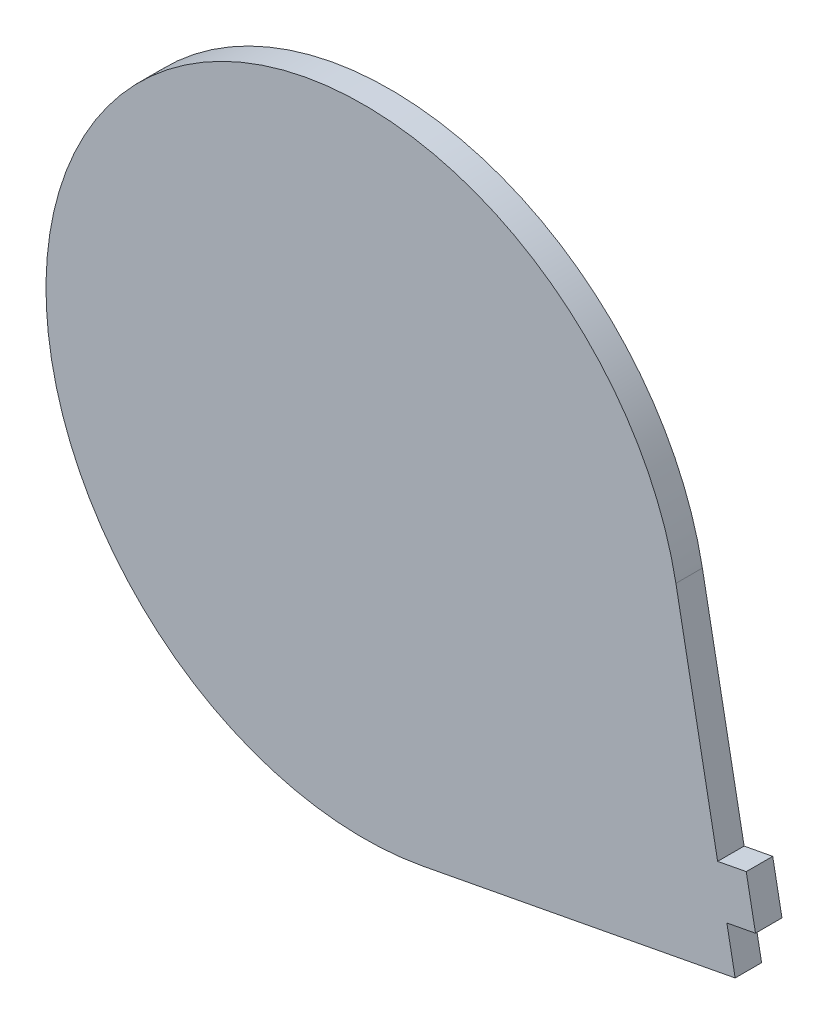
from build123d import *

# Parameters (mm, degrees)
BOSS_EXTRUDE1_DEPTH = 5


with BuildPart() as part:
    # Sketch1 → Boss-Extrude1 (new body)
    with BuildSketch(Plane.XY):
        with BuildLine():
            Line((58.948050608, 11.186032786), (66.828328123, -30.341379713))
            Line((66.828328123, -30.341379713), (72.231899429, -29.315993374))
            Line((72.231899429, -29.315993374), (73.977656704, -38.515768682))
            Line((73.977656704, -38.515768682), (68.574085398, -39.541155021))
            Line((68.574085398, -39.541155021), (70.134083395, -47.762017822))
            Line((70.134083395, -47.762017822), (11.186032786, -58.948050608))
            ThreePointArc((11.186032786, -58.948050608), (-49.592285961, 33.772846685), (58.948050608, 11.186032786))
        make_face()
    extrude(amount=BOSS_EXTRUDE1_DEPTH)


solid = part.part
